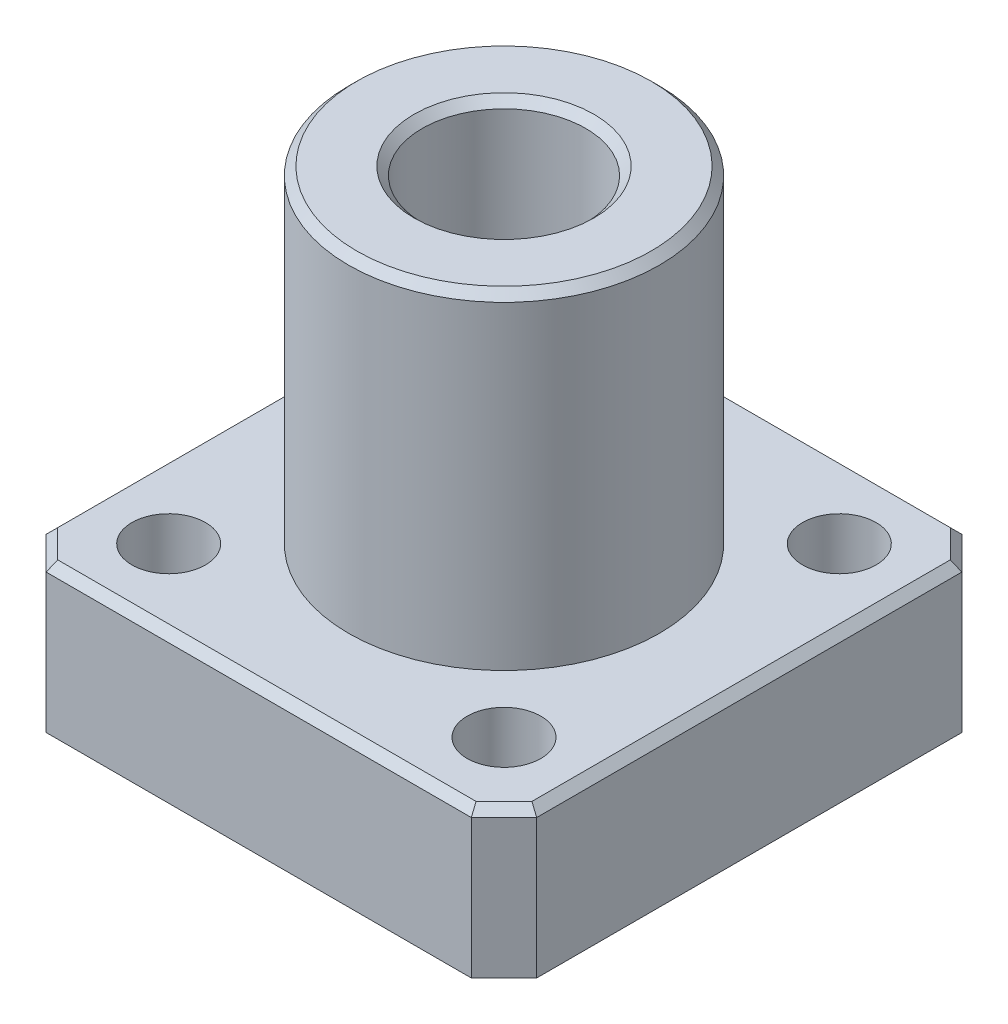
from build123d import *

# Parameters (mm, degrees)
ESQUISSE1_W      = 30
ESQUISSE1_H      = 30
ESQUISSE1_R      = 2.25
EXTRUSION1_DEPTH = 9
ESQUISSE2_R      = 9.5
EXTRUSION2_DEPTH = 20
CHANFREIN1_SIZE  = 2
EXTRUSION3_REACH = 31
ESQUISSE3_R      = 5
CHANFREIN2_SIZE  = 0.5


with BuildPart() as part:
    # Esquisse1 → Extrusion1 (new body)
    with BuildSketch(Plane(origin=(0, 0, 0), x_dir=(1, 0, 0), z_dir=(0, 1, 0))):
        with Locations((15, 15)):
            Rectangle(ESQUISSE1_W, ESQUISSE1_H)
        with Locations((4.746951673, 25.253048327)):
            Circle(ESQUISSE1_R, mode=Mode.SUBTRACT)
        with Locations((25.253048327, 25.253048327)):
            Circle(ESQUISSE1_R, mode=Mode.SUBTRACT)
        with Locations((25.253048327, 4.746951673)):
            Circle(ESQUISSE1_R, mode=Mode.SUBTRACT)
        with Locations((4.746951673, 4.746951673)):
            Circle(ESQUISSE1_R, mode=Mode.SUBTRACT)
    extrude(amount=EXTRUSION1_DEPTH)

    # Esquisse2 → Extrusion2 (add)
    with BuildSketch(Plane(origin=(0, 9, 0), x_dir=(1, 0, 0), z_dir=(0, 1, 0))):
        with Locations((15, 15)):
            Circle(ESQUISSE2_R)
    extrude(amount=EXTRUSION2_DEPTH)

    # Chanfrein1
    chanfrein1_edges = [part.edges().sort_by_distance(p)[0] for p in [
        (0, 4.5, -30),
        (30, 4.5, -30),
        (30, 4.5, 0),
        (0, 4.5, 0),
    ]]
    chamfer(chanfrein1_edges, length=CHANFREIN1_SIZE)

    # Esquisse3 → Extrusion3 (cut, up to next)
    with BuildSketch(Plane(origin=(0, 29, 0), x_dir=(1, 0, 0), z_dir=(0, 1, 0)), mode=Mode.PRIVATE) as extrusion3_sk1:
        with Locations((15, 15)):
            Circle(ESQUISSE3_R)
    extrusion3_tool1 = extrude(extrusion3_sk1.sketch, amount=-EXTRUSION3_REACH, mode=Mode.PRIVATE) & part.part
    add(extrusion3_tool1.solids().sort_by_distance((15, 29, -15))[0], mode=Mode.SUBTRACT)

    # Chanfrein2
    chanfrein2_edges = [part.edges().sort_by_distance(p)[0] for p in [
        (5.5, 29, -15),
        (0, 9, -15),
        (15, 9, -30),
        (15, 9, 0),
        (30, 9, -15),
        (1, 9, -1),
        (29, 9, -1),
        (29, 9, -29),
        (1, 9, -29),
        (10, 0, -15),
        (10, 29, -15),
    ]]
    chamfer(chanfrein2_edges, length=CHANFREIN2_SIZE)


solid = part.part
